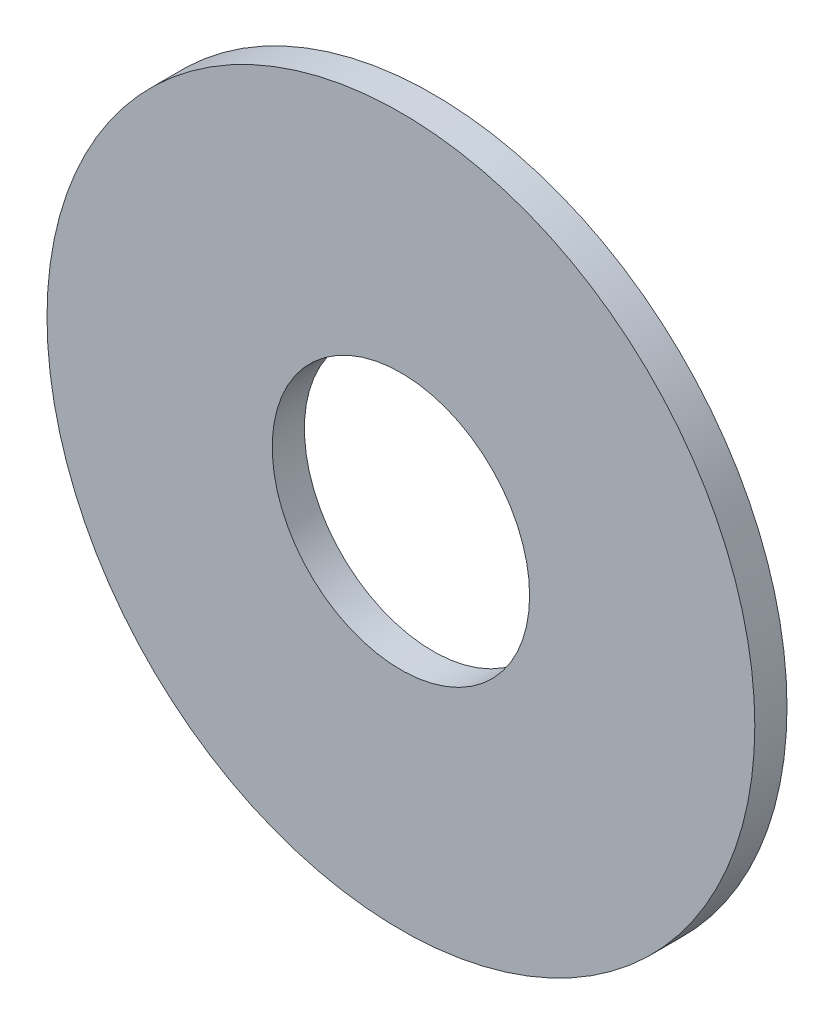
from build123d import *

# Parameters (mm, degrees)
SKETCH2_R          = 5.5
SKETCH2_R_2        = 2
BODY_EXTRUDE_DEPTH = 0.25


with BuildPart() as part:
    # Sketch2 → Body Extrude (new, symmetric)
    with BuildSketch(Plane.XY):
        Circle(SKETCH2_R)
        Circle(SKETCH2_R_2, mode=Mode.SUBTRACT)
    extrude(amount=BODY_EXTRUDE_DEPTH, both=True)


solid = part.part
